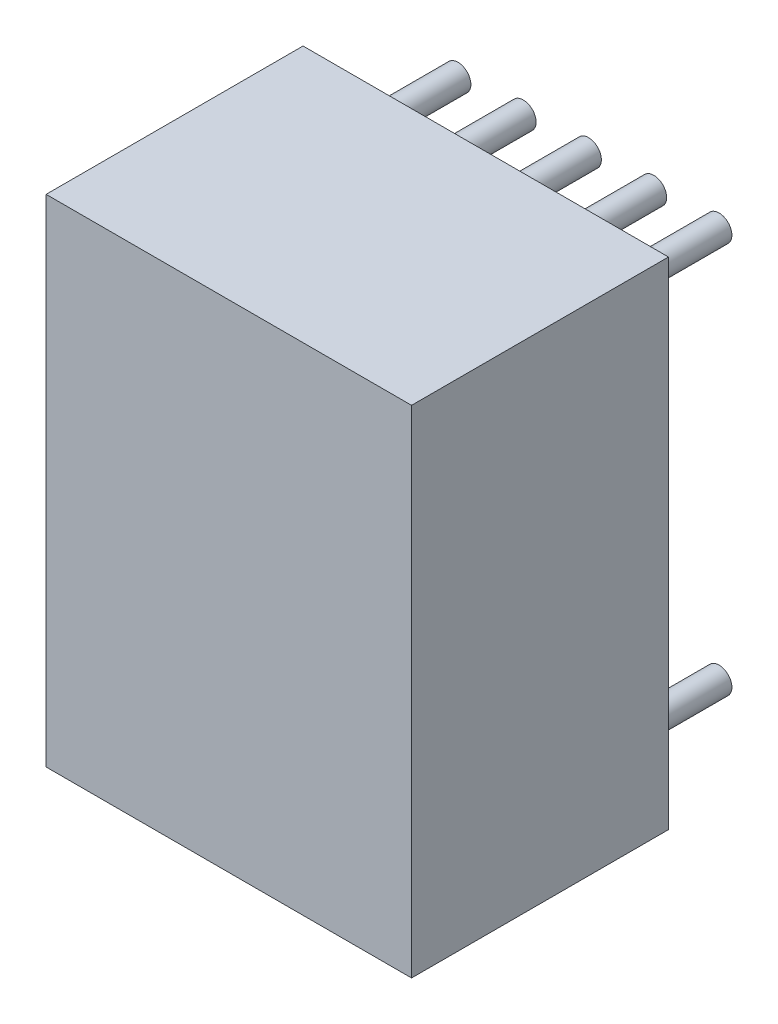
from build123d import *

# Parameters (mm, degrees)
SKETCH1_W               = 7.112
SKETCH1_H               = 9.652
COMPONENT_OUTLINE_DEPTH = 5
SKETCH2_R               = 0.25
EXTRUDE_1_DEPTH         = 2
SKETCH3_R               = 0.25
EXTRUDE_2_DEPTH         = 2
SKETCH4_R               = 0.25
EXTRUDE_3_DEPTH         = 2
SKETCH5_R               = 0.25
EXTRUDE_4_DEPTH         = 2
SKETCH6_R               = 0.25
EXTRUDE_5_DEPTH         = 2
SKETCH7_R               = 0.25
EXTRUDE_6_DEPTH         = 2
SKETCH8_R               = 0.25
EXTRUDE_7_DEPTH         = 2
SKETCH9_R               = 0.25
EXTRUDE_8_DEPTH         = 2
SKETCH10_R              = 0.25
EXTRUDE_9_DEPTH         = 2
SKETCH11_R              = 0.25
EXTRUDE_10_DEPTH        = 2


with BuildPart() as part:
    # Sketch1 → Component_Outline (new body)
    with BuildSketch(Plane.XY):
        with Locations((2.54, 3.81)):
            Rectangle(SKETCH1_W, SKETCH1_H)
    extrude(amount=COMPONENT_OUTLINE_DEPTH)


with BuildPart() as body_2:
    # Sketch2 → Extrude 1 (new body)
    with BuildSketch(Plane.XY):
        Circle(SKETCH2_R)
    extrude(amount=-EXTRUDE_1_DEPTH)


with BuildPart() as body_3:
    # Sketch3 → Extrude 2 (new body)
    with BuildSketch(Plane.XY):
        with Locations((1.27, 0)):
            Circle(SKETCH3_R)
    extrude(amount=-EXTRUDE_2_DEPTH)


with BuildPart() as body_4:
    # Sketch4 → Extrude 3 (new body)
    with BuildSketch(Plane.XY):
        with Locations((2.54, 0)):
            Circle(SKETCH4_R)
    extrude(amount=-EXTRUDE_3_DEPTH)


with BuildPart() as body_5:
    # Sketch5 → Extrude 4 (new body)
    with BuildSketch(Plane.XY):
        with Locations((3.81, 0)):
            Circle(SKETCH5_R)
    extrude(amount=-EXTRUDE_4_DEPTH)


with BuildPart() as body_6:
    # Sketch6 → Extrude 5 (new body)
    with BuildSketch(Plane.XY):
        with Locations((5.08, 0)):
            Circle(SKETCH6_R)
    extrude(amount=-EXTRUDE_5_DEPTH)


with BuildPart() as body_7:
    # Sketch7 → Extrude 6 (new body)
    with BuildSketch(Plane.XY):
        with Locations((5.08, 7.62)):
            Circle(SKETCH7_R)
    extrude(amount=-EXTRUDE_6_DEPTH)


with BuildPart() as body_8:
    # Sketch8 → Extrude 7 (new body)
    with BuildSketch(Plane.XY):
        with Locations((3.81, 7.62)):
            Circle(SKETCH8_R)
    extrude(amount=-EXTRUDE_7_DEPTH)


with BuildPart() as body_9:
    # Sketch9 → Extrude 8 (new body)
    with BuildSketch(Plane.XY):
        with Locations((2.54, 7.62)):
            Circle(SKETCH9_R)
    extrude(amount=-EXTRUDE_8_DEPTH)


with BuildPart() as body_10:
    # Sketch10 → Extrude 9 (new body)
    with BuildSketch(Plane.XY):
        with Locations((1.27, 7.62)):
            Circle(SKETCH10_R)
    extrude(amount=-EXTRUDE_9_DEPTH)


with BuildPart() as body_11:
    # Sketch11 → Extrude 10 (new body)
    with BuildSketch(Plane.XY):
        with Locations((0, 7.62)):
            Circle(SKETCH11_R)
    extrude(amount=-EXTRUDE_10_DEPTH)


solid = Compound([part.part, body_2.part, body_3.part, body_4.part, body_5.part, body_6.part, body_7.part, body_8.part, body_9.part, body_10.part, body_11.part])
